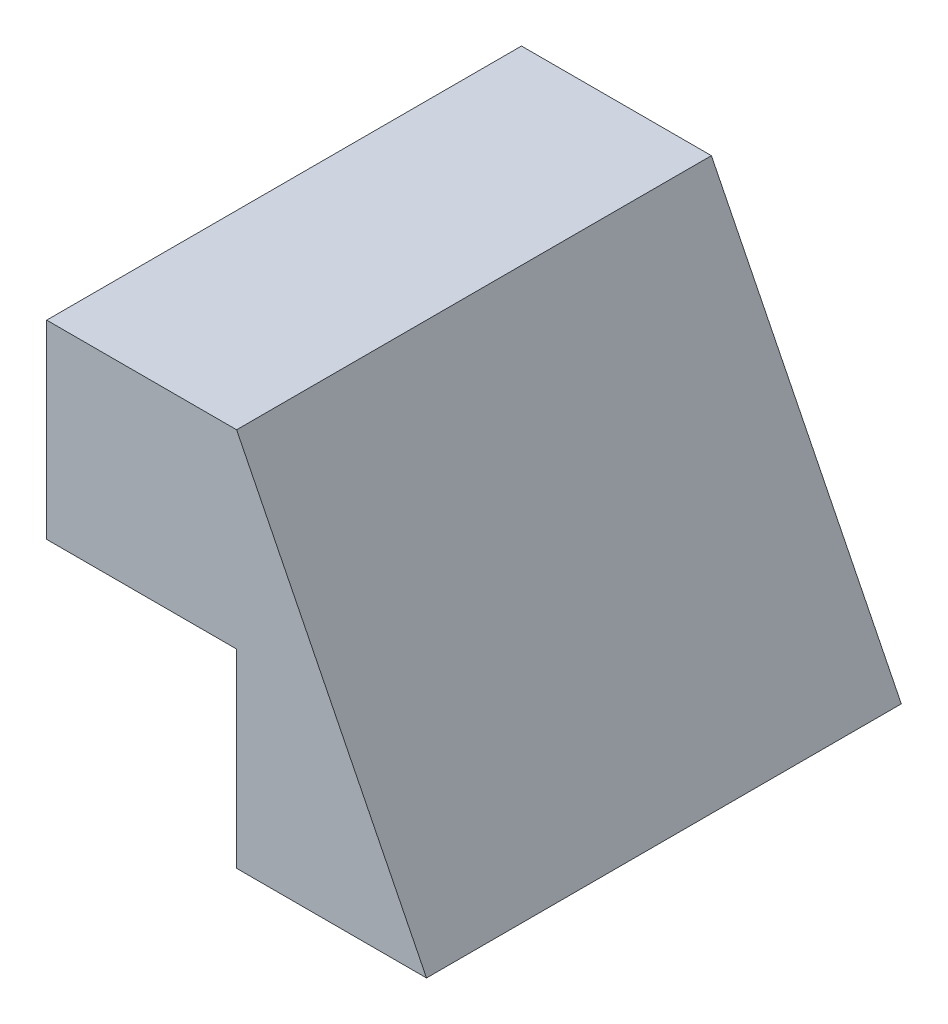
from build123d import *

# Parameters (mm, degrees)
BOSS_EXTRUDE1_DEPTH = 25


with BuildPart() as part:
    # Sketch1 → Boss-Extrude1 (new body)
    with BuildSketch(Plane.XY):
        Polygon((-10, 20), (0, 20), (10, 0), (0, 0), (0, 10), (-10, 10), align=None)
    extrude(amount=BOSS_EXTRUDE1_DEPTH)


solid = part.part
